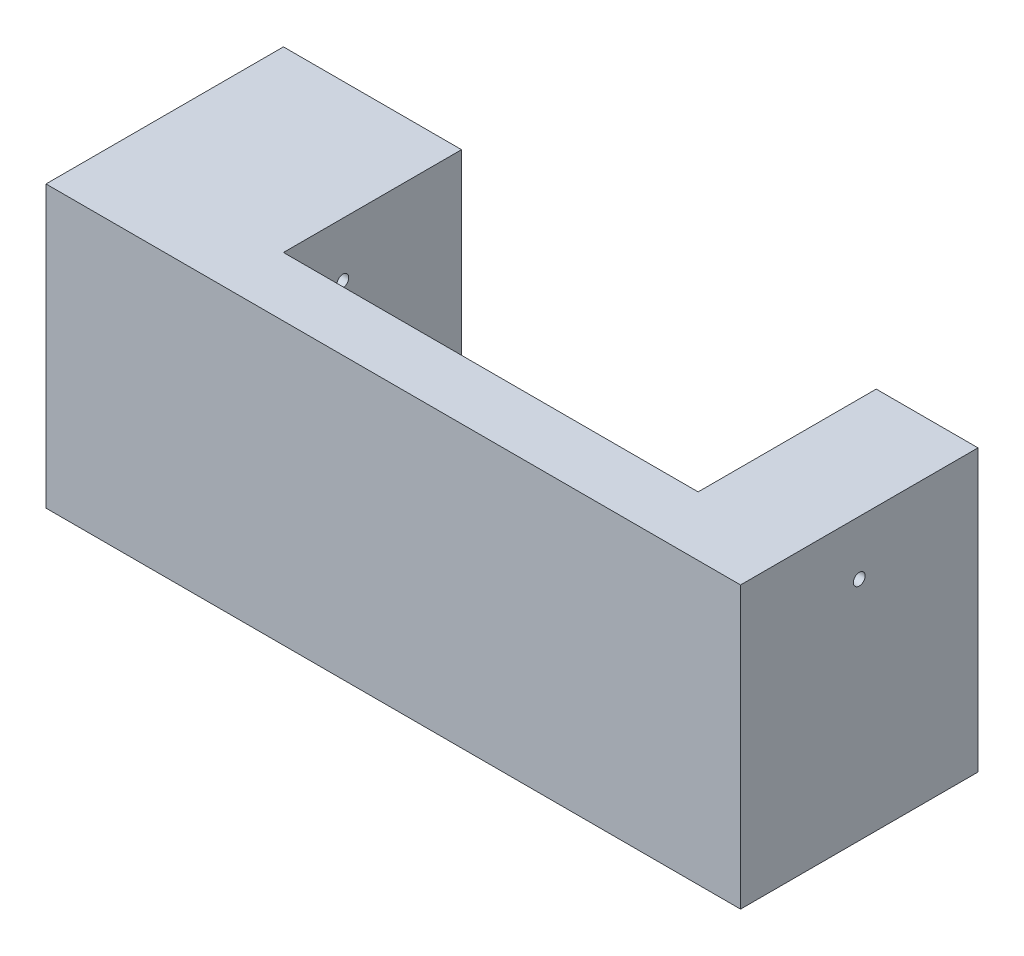
from build123d import *

# Parameters (mm, degrees)
CROQUIS1_W              = 40
CROQUIS1_H              = 47.3
CROQUIS1_R              = 1
SALIENTE_EXTRUIR1_DEPTH = 30
CROQUIS2_W              = 10
CROQUIS2_H              = 47.3
SALIENTE_EXTRUIR2_DEPTH = 87
CROQUIS3_W              = 17.14601676
CROQUIS3_H              = 47.3
SALIENTE_EXTRUIR3_DEPTH = 30
CROQUIS4_R              = 1
CORTAR_EXTRUIR1_DEPTH   = 118


with BuildPart() as part:
    # Croquis1 → Saliente-Extruir1 (new body)
    with BuildSketch(Plane(origin=(0, 0, 0), x_dir=(0, 0, -1), z_dir=(1, 0, 0))):
        Rectangle(CROQUIS1_W, CROQUIS1_H)
        with Locations((0, 14.489311164)):
            Circle(CROQUIS1_R, mode=Mode.SUBTRACT)
    extrude(amount=SALIENTE_EXTRUIR1_DEPTH)

    # Croquis2 → Saliente-Extruir2 (add)
    with BuildSketch(Plane(origin=(30, 0, 0), x_dir=(0, 0, -1), z_dir=(1, 0, 0))):
        with Locations((-15, 0)):
            Rectangle(CROQUIS2_W, CROQUIS2_H)
    extrude(amount=SALIENTE_EXTRUIR2_DEPTH)

    # Croquis3 → Saliente-Extruir3 (add)
    with BuildSketch(Plane(origin=(0, 0, 10), x_dir=(-1, 0, 0), z_dir=(0, 0, -1))):
        with Locations((-108.42699162, 0)):
            Rectangle(CROQUIS3_W, CROQUIS3_H)
    extrude(amount=SALIENTE_EXTRUIR3_DEPTH)

    # Croquis4 → Cortar-Extruir1 (cut, through all)
    with BuildSketch(Plane.ZY):
        with Locations((0, 14.489311164)):
            Circle(CROQUIS4_R)
    extrude(amount=-CORTAR_EXTRUIR1_DEPTH, mode=Mode.SUBTRACT)


solid = part.part
